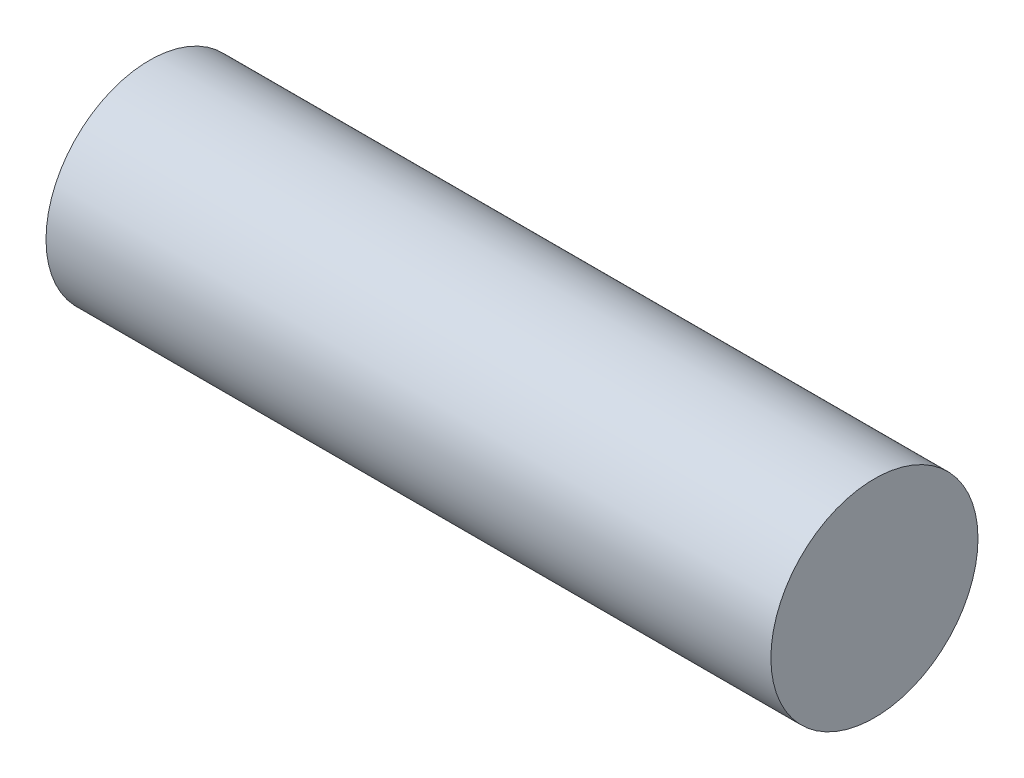
from build123d import *

# Parameters (mm, degrees)
SKETCH1_R      = 12.7
EXTRUDE1_DEPTH = 44.45


with BuildPart() as part:
    # Sketch1 → Extrude1 (new body, symmetric)
    with BuildSketch(Plane(origin=(0, 0, 0), x_dir=(0, 0, -1), z_dir=(1, 0, 0))):
        Circle(SKETCH1_R)
    extrude(amount=EXTRUDE1_DEPTH, both=True)


solid = part.part
